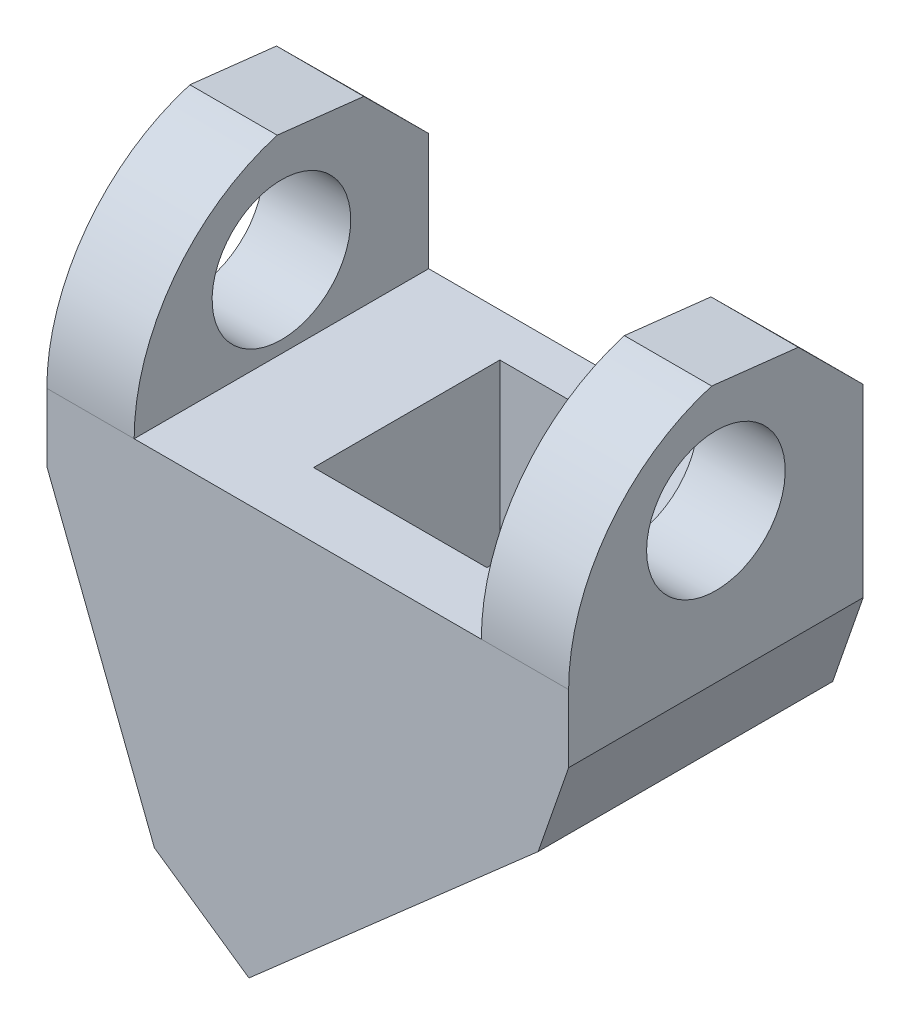
from build123d import *

# Parameters (mm, degrees)
BOSS_EXTRUDE1_DEPTH     = 17
CUT_EXTRUDE1_DEPTH      = 44
CUT_EXTRUDE1_DEPTH_BACK = 15
SKETCH3_W               = 9.47
SKETCH3_H               = 10.75
CUT_EXTRUDE2_REACH      = 25.642
SKETCH5_W               = 10
SKETCH5_H               = 10.75
SKETCH6_R               = 4
CUT_EXTRUDE3_DEPTH      = 20


with BuildPart() as part:
    # Sketch1 → Boss-Extrude1 (new body)
    with BuildSketch(Plane.XY):
        Polygon((-16.550185094, 16.389351475), (-16.550185094, 1.389351475), (-10.343680533, -14.570648525), (-4.883984447, -18.349711721), (11.8091046, -3.684474659), (13.567850846, 1.389351475), (13.567850846, 16.389351475), (8.527850846, 16.389351475), (8.527850846, 5.292351475), (-11.510185094, 5.292351475), (-11.510185094, 16.389351475), align=None)
    extrude(amount=BOSS_EXTRUDE1_DEPTH)

    # Sketch2 → Cut-Extrude1 (cut, two sides)
    with BuildSketch(Plane(origin=(-11.510185094, 0, 0), x_dir=(0, 0, -1), z_dir=(1, 0, 0))) as cut_extrude1_sk:
        with BuildLine():
            Line((-17, 16.389351475), (-17, 5.292351475))
            ThreePointArc((-17, 5.292351475), (-14.707938783, 12.187976499), (-8.743930787, 16.339337446))
            Line((-8.743930787, 16.339337446), (-3.743930787, 15.776730228))
            Line((-3.743930787, 15.776730228), (0, 12.052351475))
            Line((0, 12.052351475), (0, 16.389351475))
            Line((0, 16.389351475), (-17, 16.389351475))
        make_face()
    extrude(amount=CUT_EXTRUDE1_DEPTH, mode=Mode.SUBTRACT)
    extrude(cut_extrude1_sk.sketch, amount=-CUT_EXTRUDE1_DEPTH_BACK, mode=Mode.SUBTRACT)

    # Cut-Sweep1: sweep along a path in Sketch4
    with BuildLine(Plane(origin=(0, 0, 10), x_dir=(-1, 0, 0), z_dir=(0, 0, -1))) as cut_sweep1_path:
        Line((0.820338721, -14.779711721), (9.490783662, -9.250648525))
    # Sketch3 → Cut-Sweep1 (sweep, cut)
    with BuildSketch(Plane(origin=(6.970965598, -7.934883628, 0), x_dir=(0.751264134, 0.660001668, 0), z_dir=(0.660001668, -0.751264134, 0))):
        with Locations((-7.025002686, 7.885)):
            Rectangle(SKETCH3_W, SKETCH3_H)
    sweep(path=cut_sweep1_path.line, mode=Mode.SUBTRACT)

    # Cut-Extrude2: up to this face of the body (flat: up to its plane)
    cut_extrude2_end = Plane(part.part.faces().sort_by_distance((-6.1991251, -12.931973418, 7.885))[0])
    # Sketch5 → Cut-Extrude2 (cut, up to the picked face)
    with BuildSketch(Plane(origin=(0, 5.292351475, 0), x_dir=(1, 0, 0), z_dir=(0, 1, 0)), mode=Mode.PRIVATE) as cut_extrude2_sk1:
        with Locations((0.107850846, -7.885)):
            Rectangle(SKETCH5_W, SKETCH5_H)
    cut_extrude2_tool1 = split(extrude(cut_extrude2_sk1.sketch, amount=-CUT_EXTRUDE2_REACH, mode=Mode.PRIVATE), bisect_by=cut_extrude2_end, keep=Keep.BOTH, mode=Mode.PRIVATE)
    add(cut_extrude2_tool1.solids().sort_by_distance((0.107851, 5.292351, 7.885))[0], mode=Mode.SUBTRACT)

    # Sketch6 → Cut-Extrude3 (cut, symmetric)
    with BuildSketch(Plane(origin=(-1.491167124, 0, 0), x_dir=(0, 0, -1), z_dir=(1, 0, 0))):
        with Locations((-8.5, 9.989351475)):
            Circle(SKETCH6_R)
    extrude(amount=CUT_EXTRUDE3_DEPTH, both=True, mode=Mode.SUBTRACT)


solid = part.part
